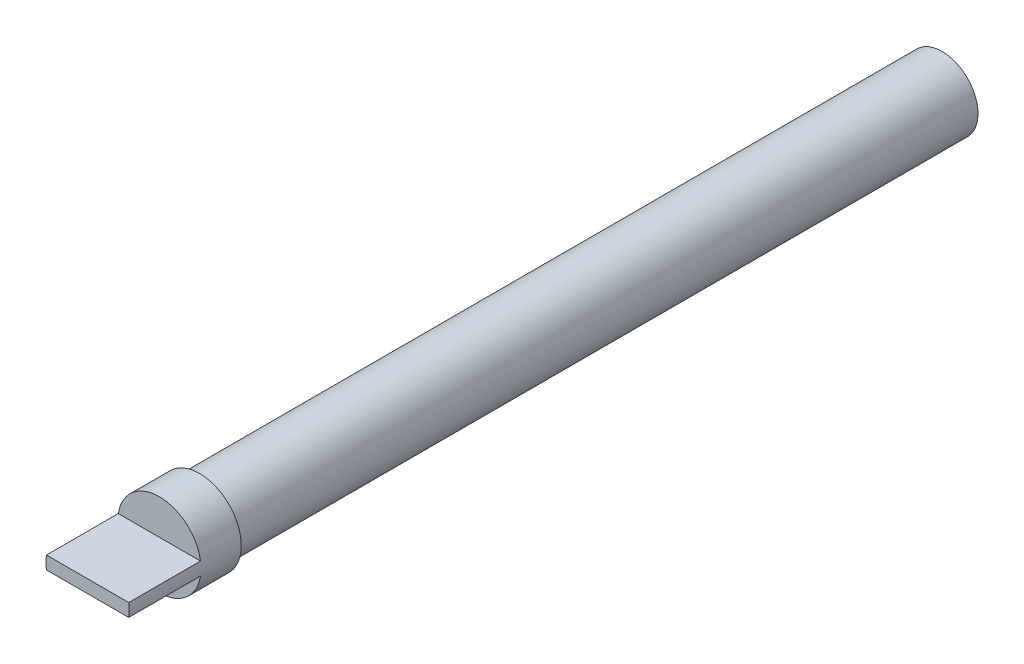
from build123d import *

# Parameters (mm, degrees)
SZKIC1_R                    = 2.9
DODANIE_WYCI_GNI_CIE1_DEPTH = 7.8
WYTNIJ_WYCI_GNI_CIE1_DEPTH  = 5
SZKIC3_R                    = 2.5
DODANIE_WYCI_GNI_CIE2_DEPTH = 51.7


with BuildPart() as part:
    # Szkic1 → Dodanie-wyciągnięcie1 (new body)
    with BuildSketch(Plane.XY):
        Circle(SZKIC1_R)
    extrude(amount=DODANIE_WYCI_GNI_CIE1_DEPTH)

    # Szkic2 → Wytnij-wyciągnięcie1 (cut)
    with BuildSketch(Plane.XY.offset(7.8)):
        Polygon((0, -0.45), (2.86487347, -0.45), (2.86487347, -2.9), (-2.9, -2.9), (-2.9, -0.45), align=None)
        Polygon((0, 0.45), (2.86487347, 0.45), (2.86487347, 2.9), (-3.305563266, 2.9), (-3.305563266, 0.45), align=None)
    extrude(amount=-WYTNIJ_WYCI_GNI_CIE1_DEPTH, mode=Mode.SUBTRACT)

    # Szkic3 → Dodanie-wyciągnięcie2 (add)
    with BuildSketch(Plane(origin=(0, 0, 0), x_dir=(-1, 0, 0), z_dir=(0, 0, -1))):
        Circle(SZKIC3_R)
    extrude(amount=DODANIE_WYCI_GNI_CIE2_DEPTH)

    # Szkic7 → Otwór Ø3.5 (3.5)2 (revolve, cut)
    with BuildSketch(Plane(origin=(0, 0, -51.7), x_dir=(0, 1, 0), z_dir=(1, 0, 0))):
        Polygon((0, 0), (0, 18.051506083), (1.75, 17), (1.75, 0), align=None)
    revolve(axis=Axis((0, 0, -58.05), (0, 0, 1)), mode=Mode.SUBTRACT)


solid = part.part
